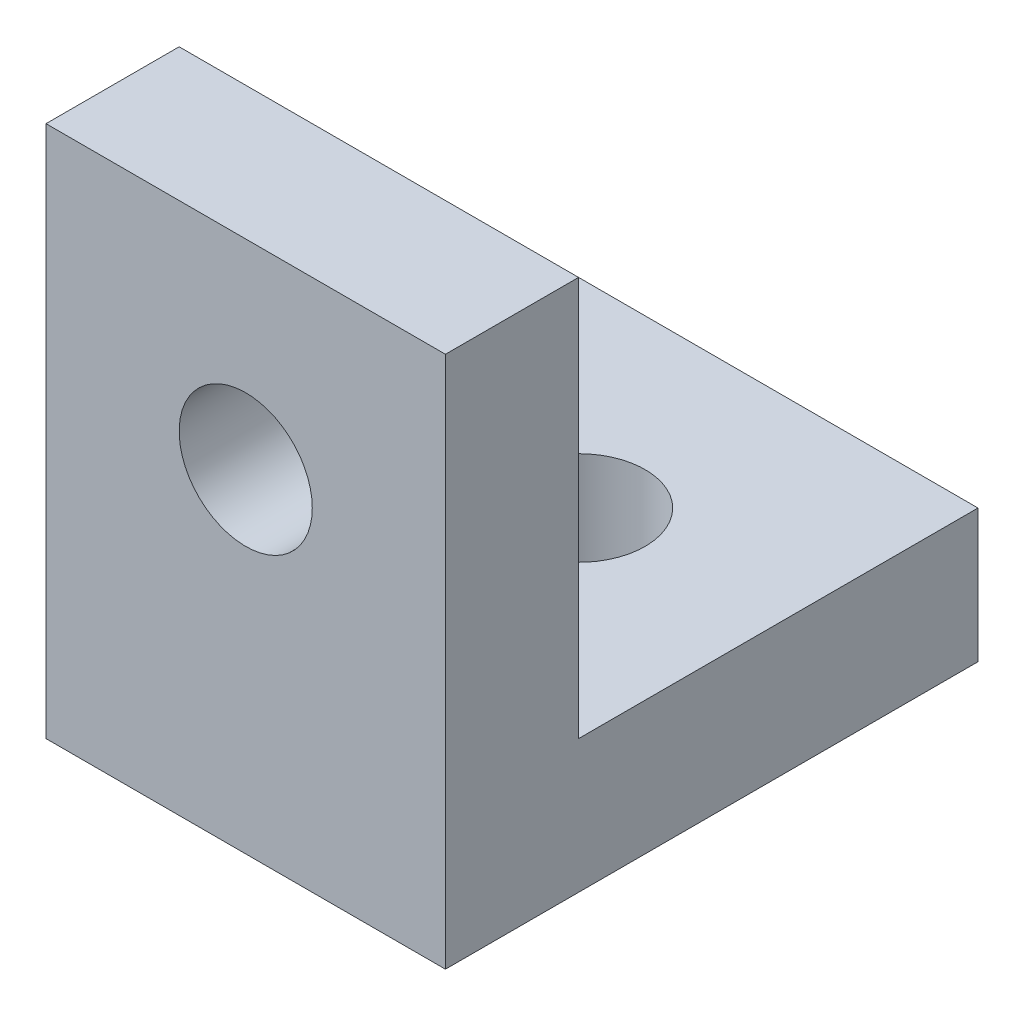
from build123d import *

# Parameters (mm, degrees)
SKETCH1_W           = 30
SKETCH1_H           = 30
BOSS_EXTRUDE1_DEPTH = 10
SKETCH4_W           = 30
SKETCH4_H           = 40
BOSS_EXTRUDE2_DEPTH = 10
SKETCH5_R           = 5
CUT_EXTRUDE1_DEPTH  = 10
SKETCH6_R           = 5
CUT_EXTRUDE2_DEPTH  = 10


with BuildPart() as part:
    # Sketch1 → Boss-Extrude1 (new body)
    with BuildSketch(Plane(origin=(0, 0, 0), x_dir=(1, 0, 0), z_dir=(0, 1, 0))):
        with Locations((15, 15)):
            Rectangle(SKETCH1_W, SKETCH1_H)
    extrude(amount=BOSS_EXTRUDE1_DEPTH)

    # Sketch4 → Boss-Extrude2 (add)
    with BuildSketch(Plane.XY):
        with Locations((15, 20)):
            Rectangle(SKETCH4_W, SKETCH4_H)
    extrude(amount=BOSS_EXTRUDE2_DEPTH)

    # Sketch5 → Cut-Extrude1 (cut)
    with BuildSketch(Plane.XY.offset(10)):
        with Locations((15, 25)):
            Circle(SKETCH5_R)
    extrude(amount=-CUT_EXTRUDE1_DEPTH, mode=Mode.SUBTRACT)

    # Sketch6 → Cut-Extrude2 (cut)
    with BuildSketch(Plane(origin=(0, 10, 0), x_dir=(1, 0, 0), z_dir=(0, 1, 0))):
        with Locations((15, 15)):
            Circle(SKETCH6_R)
    extrude(amount=-CUT_EXTRUDE2_DEPTH, mode=Mode.SUBTRACT)


solid = part.part
